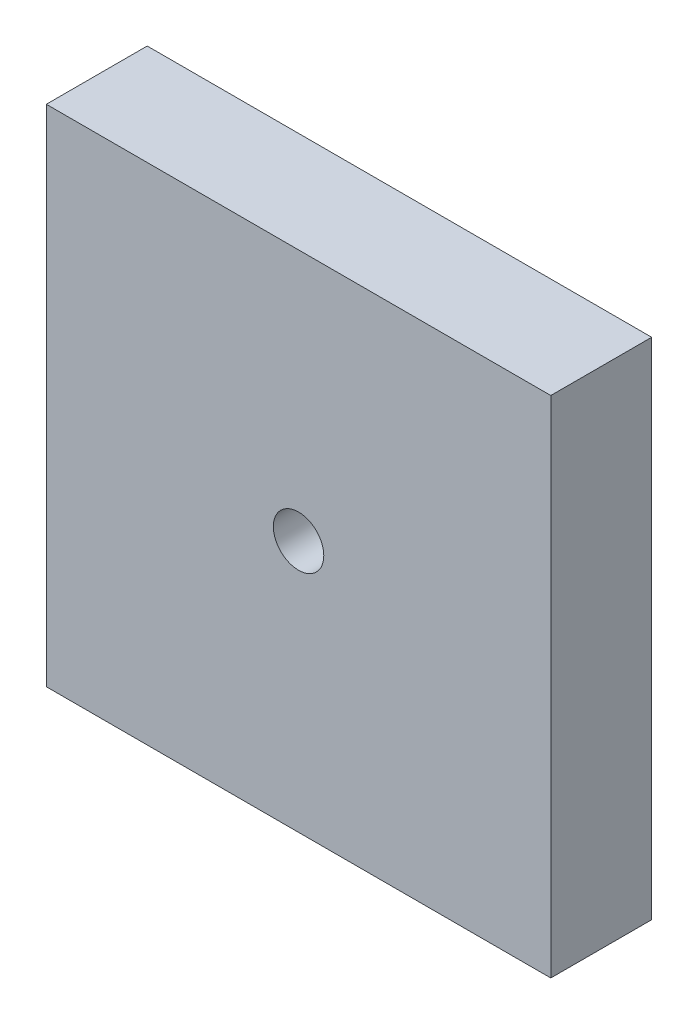
from build123d import *

# Parameters (mm, degrees)
SKETCH_2_W      = 10
SKETCH_2_H      = 10
SKETCH_2_R      = 0.5
EXTRUDE_1_DEPTH = 2


with BuildPart() as part:
    # ｽｹｯﾁ2 → ﾎﾞｽ - 押し出し1 (new body)
    with BuildSketch(Plane.XY):
        Rectangle(SKETCH_2_W, SKETCH_2_H)
        Circle(SKETCH_2_R, mode=Mode.SUBTRACT)
    extrude(amount=EXTRUDE_1_DEPTH)


solid = part.part
